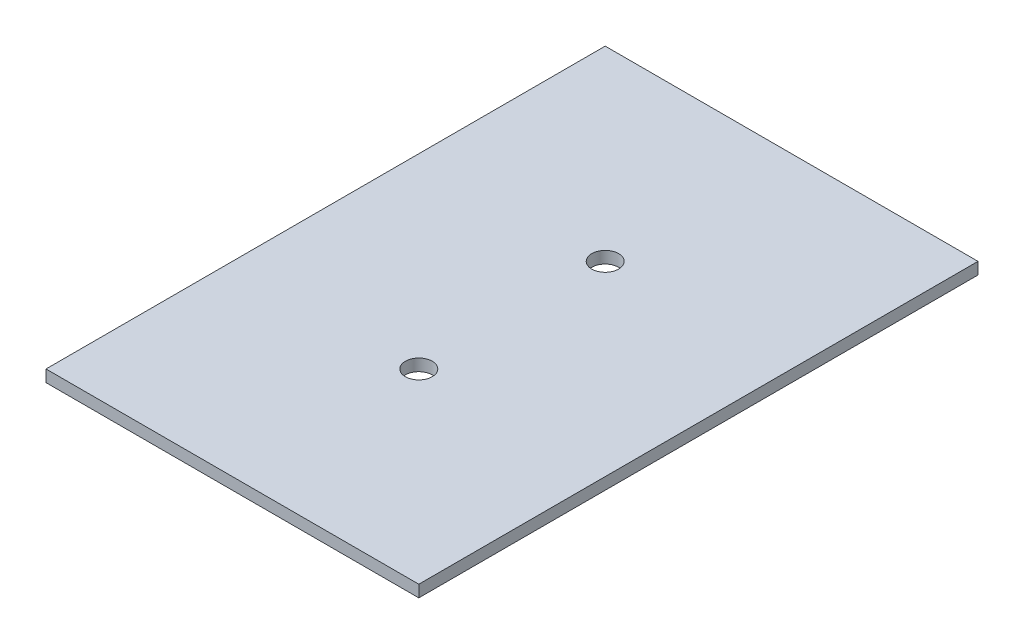
from build123d import *

# Parameters (mm, degrees)
SKETCH1_W           = 44
SKETCH1_H           = 66
BOSS_EXTRUDE1_DEPTH = 1.4
SKETCH2_R           = 1.585
CUT_EXTRUDE1_DEPTH  = 2.4


with BuildPart() as part:
    # Sketch1 → Boss-Extrude1 (new body)
    with BuildSketch(Plane(origin=(0, 0, 0), x_dir=(1, 0, 0), z_dir=(0, 1, 0))):
        Rectangle(SKETCH1_W, SKETCH1_H)
    extrude(amount=BOSS_EXTRUDE1_DEPTH)

    # Sketch2 → Cut-Extrude1 (cut, through all)
    with BuildSketch(Plane(origin=(0, 1.4, 0), x_dir=(1, 0, 0), z_dir=(0, 1, 0))):
        with Locations((0, 11)):
            Circle(SKETCH2_R)
        with Locations((0, -11)):
            Circle(SKETCH2_R)
    extrude(amount=-CUT_EXTRUDE1_DEPTH, mode=Mode.SUBTRACT)


solid = part.part
